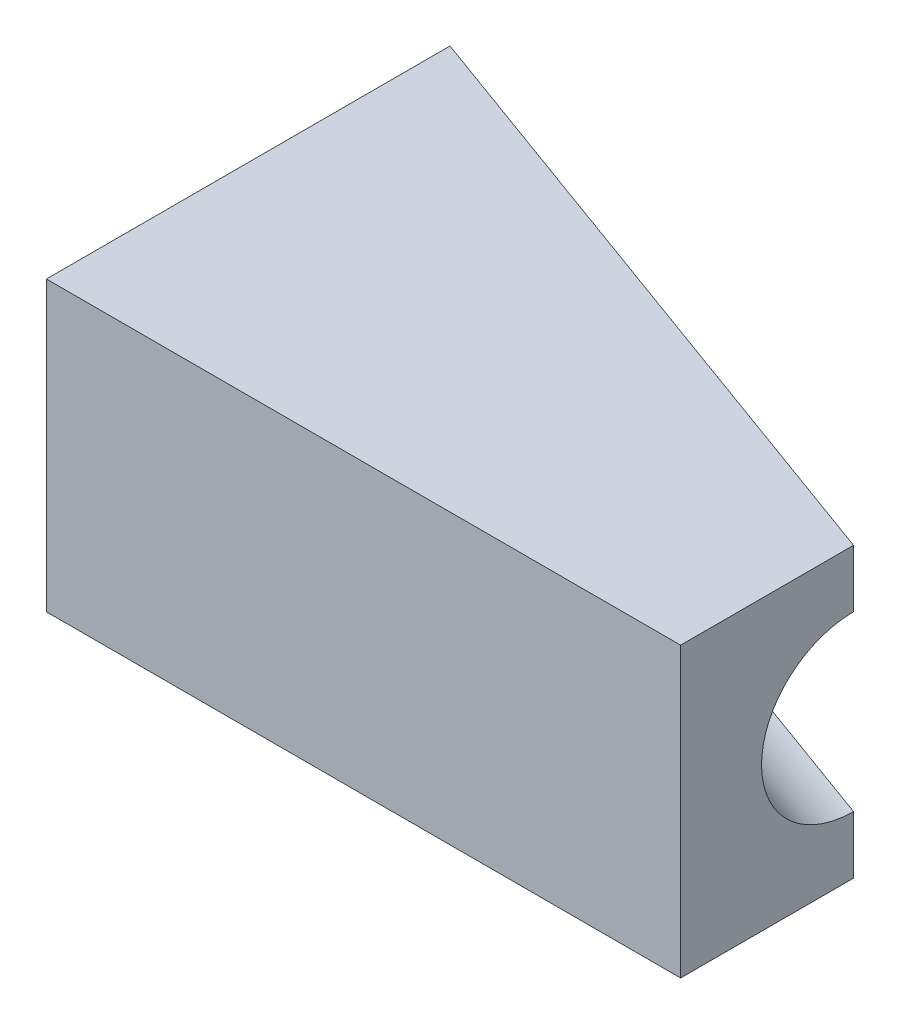
from build123d import *

# Parameters (mm, degrees)
BOSS_EXTRUDE1_DEPTH = 50
SKETCH3_R           = 15
CUT_EXTRUDE2_DEPTH  = 128.299291


with BuildPart() as part:
    # Sketch2 → Boss-Extrude1 (new body)
    with BuildSketch(Plane(origin=(0, 0, 0), x_dir=(1, 0, 0), z_dir=(0, 1, 0))):
        Polygon((0, 0), (0, 40), (110, 0), (110, -30), (0, -30), align=None)
    extrude(amount=BOSS_EXTRUDE1_DEPTH)

    # Sketch3 → Cut-Extrude2 (cut, through all)
    with BuildSketch(Plane(origin=(-12.846715328, 0, -4.671532847), x_dir=(0.341743063, 0, -0.939793423), z_dir=(0.939793423, 0, 0.341743063))):
        with Locations((37.59173694, 25)):
            Circle(SKETCH3_R)
    extrude(amount=CUT_EXTRUDE2_DEPTH, mode=Mode.SUBTRACT)


solid = part.part
